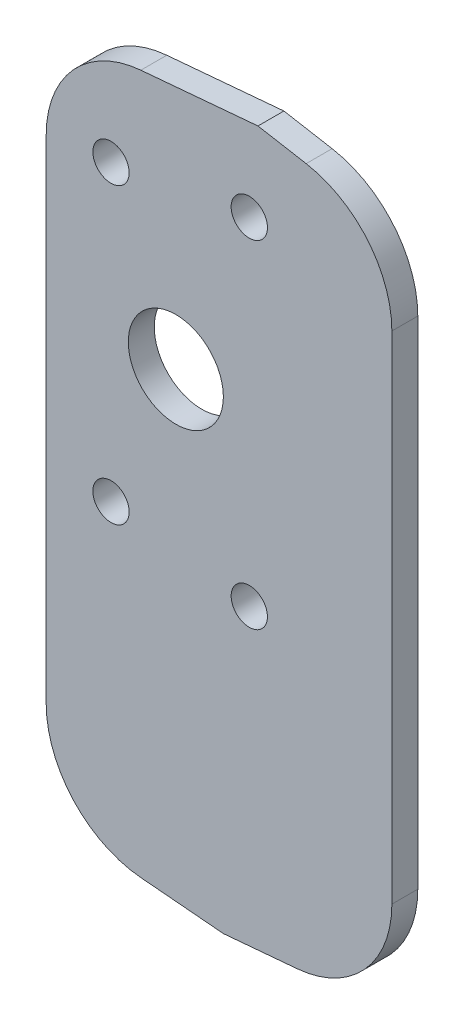
from build123d import *

# Parameters (mm, degrees)
EXTRUSION1_DEPTH          = 3
ESQUISSE3_R               = 5.5
ENL_V_MAT_EXTRU_1_DEPTH   = 4
CONG_1_R                  = 12
TROU_TARAUD_M5X0_82_D     = 4.2
TROU_TARAUD_M5X0_82_DEPTH = 3
TROU_TARAUD_M5X0_82_TIP   = 1.2618073


with BuildPart() as part:
    # Esquisse2 → Extrusion1 (new body)
    with BuildSketch(Plane.XY):
        Polygon((-5.959878762, 64.527559487), (18.544923687, 66.671451903), (34.040121238, 63.939230504), (34.040121238, -14.560769496), (14.544923687, -16.266378275), (-5.959878762, -14.472440513), align=None)
    extrude(amount=EXTRUSION1_DEPTH)

    # Esquisse3 → Enlèv. mat.-Extru.1 (cut, through all)
    with BuildSketch(Plane.XY.offset(3)):
        with Locations((9.040121238, 37.527559487)):
            Circle(ESQUISSE3_R)
    extrude(amount=-ENL_V_MAT_EXTRU_1_DEPTH, mode=Mode.SUBTRACT)

    # Congé1
    cong_1_edges = [part.edges().sort_by_distance(p)[0] for p in [
        (-5.959878762, 64.527559487, 1.5),
        (-5.959878762, -14.472440513, 1.5),
        (34.040121238, 63.939230504, 1.5),
        (34.040121238, -14.560769496, 1.5),
    ]]
    fillet(cong_1_edges, radius=CONG_1_R)

    # Trou taraudé M5x0.82
    with Locations(Plane(origin=(1.540121238, 54.527559487, 3), x_dir=(1, 0, 0), z_dir=(0, 0, 1))):
        with Locations((0, 0), (16, 2.5), (0, -34), (16, -36.5)):
            Hole(TROU_TARAUD_M5X0_82_D / 2, depth=TROU_TARAUD_M5X0_82_DEPTH)
            with Locations((0, 0, -(TROU_TARAUD_M5X0_82_DEPTH + TROU_TARAUD_M5X0_82_TIP / 2))):  # 118° drill point
                Cone(0, TROU_TARAUD_M5X0_82_D / 2, TROU_TARAUD_M5X0_82_TIP, mode=Mode.SUBTRACT)


solid = part.part
